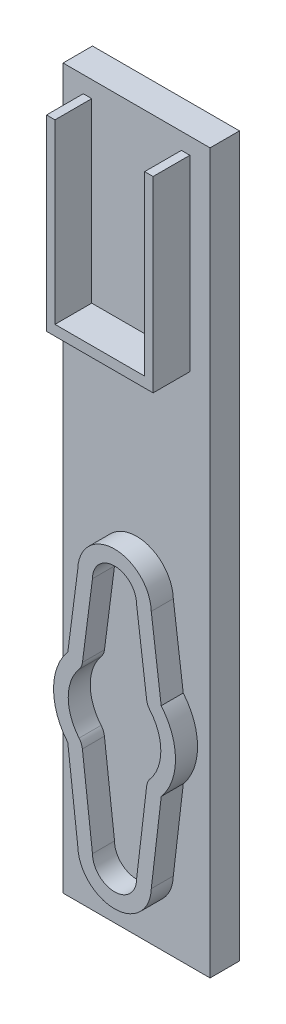
from build123d import *

# Parameters (mm, degrees)
BOSS_EXTRUDE1_DEPTH = 3
BOSS_EXTRUDE2_DEPTH = 4
BOSS_EXTRUDE3_DEPTH = 5


with BuildPart() as part:
    # Sketch1 → Boss-Extrude1 (new body)
    with BuildSketch(Plane.XY):
        with BuildLine():
            Line((-6.349735442, 5.345171636), (-4.997891213, 15.788269553))
            ThreePointArc((-4.997891213, 15.788269553), (0, 20.643068224), (4.997891213, 15.788269553))
            Line((4.997891213, 15.788269553), (6.349735442, 5.345171636))
            ThreePointArc((6.349735442, 5.345171636), (8.299997248, 0.006758739), (6.358432228, -5.334823296))
            Line((6.358432228, -5.334823296), (4.998253221, -16.889085995))
            ThreePointArc((4.998253221, -16.889085995), (0, -21.756931776), (-4.998253221, -16.889085995))
            Line((-4.998253221, -16.889085995), (-6.358432228, -5.334823296))
            ThreePointArc((-6.358432228, -5.334823296), (-8.299997248, 0.006758739), (-6.349735442, 5.345171636))
        make_face()
        with BuildLine():
            Line((-4.36628468, 5.088416745), (-3, 15.643068224))
            ThreePointArc((-3, 15.643068224), (0, 18.643068224), (3, 15.643068224))
            Line((3, 15.643068224), (4.36628468, 5.088416745))
            ThreePointArc((4.36628468, 5.088416745), (4.518875856, 4.540216249), (4.819678709, 4.057178471))
            ThreePointArc((4.819678709, 4.057178471), (6.299997911, 0.005130128), (4.826279884, -4.049323707))
            ThreePointArc((4.826279884, -4.049323707), (4.522307907, -4.541950371), (4.37214806, -5.100995998))
            Line((4.37214806, -5.100995998), (3, -16.756931776))
            ThreePointArc((3, -16.756931776), (0, -19.756931776), (-3, -16.756931776))
            Line((-3, -16.756931776), (-4.37214806, -5.100995998))
            ThreePointArc((-4.37214806, -5.100995998), (-4.522307907, -4.541950371), (-4.826279884, -4.049323707))
            ThreePointArc((-4.826279884, -4.049323707), (-6.299997911, 0.005130128), (-4.819678709, 4.057178471))
            ThreePointArc((-4.819678709, 4.057178471), (-4.518875856, 4.540216249), (-4.36628468, 5.088416745))
        make_face(mode=Mode.SUBTRACT)
    extrude(amount=BOSS_EXTRUDE1_DEPTH)

    # Sketch2 → Boss-Extrude2 (add)
    with BuildSketch(Plane(origin=(0, 0, 0), x_dir=(-1, 0, 0), z_dir=(0, 0, -1))):
        Polygon((10, -26.40946304), (-10, -26.40946304), (-10, 26.40946304), (-10, 71.40946304), (10, 71.40946304), (10, 26.40946304), align=None)
    extrude(amount=BOSS_EXTRUDE2_DEPTH)

    # Sketch3 → Boss-Extrude3 (add)
    with BuildSketch(Plane.XY):
        Polygon((7.25, 69.15946304), (6.1, 69.15946304), (6.1, 67.75946304), (6.1, 45.05946304), (-6.1, 45.05946304), (-6.1, 67.75946304), (-6.1, 69.15946304), (-7.25, 69.15946304), (-7.25, 43.65946304), (7.25, 43.65946304), align=None)
    extrude(amount=BOSS_EXTRUDE3_DEPTH)


solid = part.part
